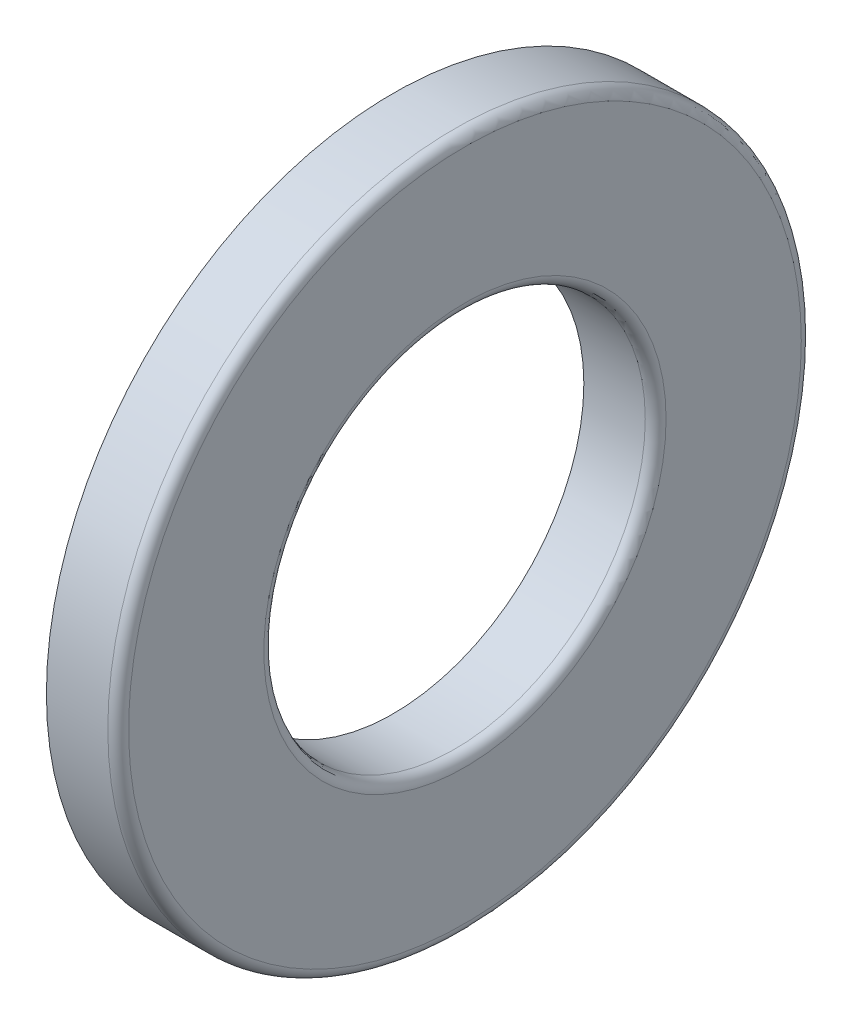
from build123d import *


with BuildPart() as part:
    # Croquis1 → Revolución1 (revolve)
    with BuildSketch(Plane.XY):
        with BuildLine():
            Line((9.858, 11), (13.4, 11))
            ThreePointArc((13.4, 11), (13.824264069, 11.175735931), (14, 11.6))
            Line((14, 11.6), (14, 19.4))
            ThreePointArc((14, 19.4), (13.824264069, 19.824264069), (13.4, 20))
            Line((13.4, 20), (9.858, 20))
            Line((9.858, 20), (9.858, 17.142666563))
            ThreePointArc((9.858, 17.142666563), (10.572, 15), (9.858, 12.857333437))
            Line((9.858, 12.857333437), (9.858, 11))
        make_face()
    revolve(axis=Axis((13.4, 0, 0), (-1, 0, 0)))


solid = part.part
